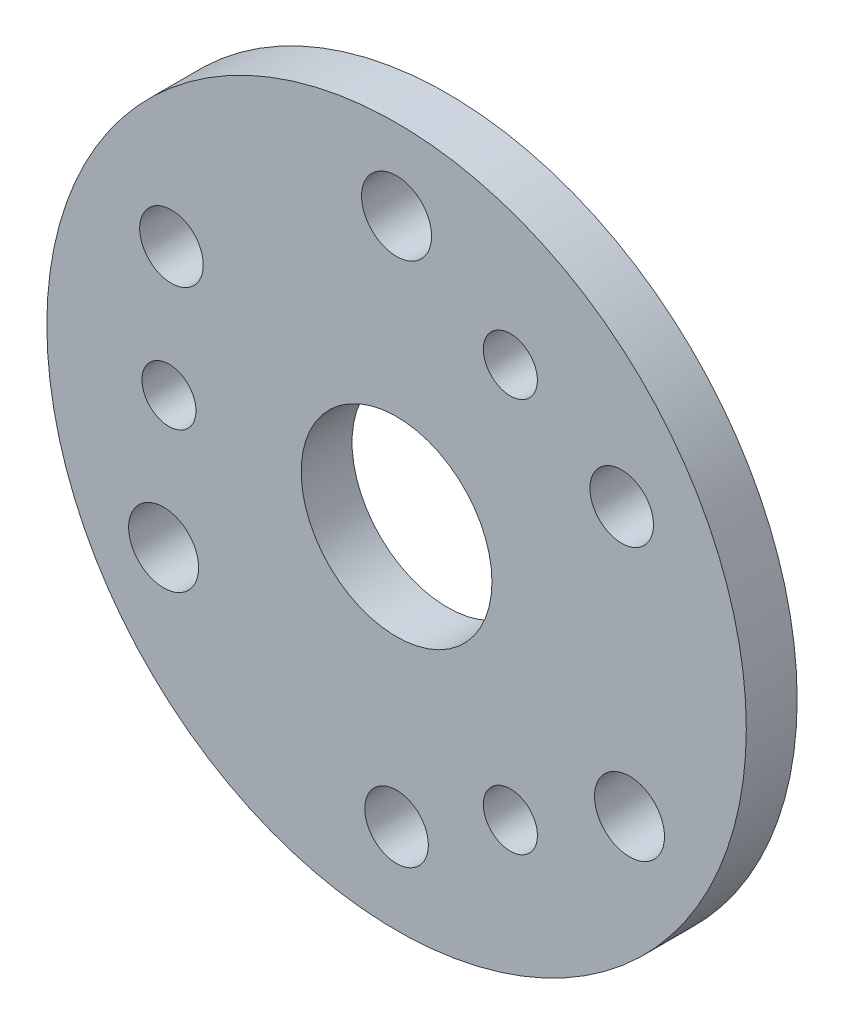
from build123d import *

# Parameters (mm, degrees)
ESQUISSE1_R        = 55
ESQUISSE1_R_2      = 15
ESQUISSE1_R_3      = 5.5
ESQUISSE1_R_4      = 4.25
ESQUISSE1_R_5      = 5
BOSS_EXTRU_1_DEPTH = 8


with BuildPart() as part:
    # Esquisse1 → Boss.-Extru.1 (new body)
    with BuildSketch(Plane.XY):
        Circle(ESQUISSE1_R)
        Circle(ESQUISSE1_R_2, mode=Mode.SUBTRACT)
        with Locations((0, 42.3)):
            Circle(ESQUISSE1_R_3, mode=Mode.SUBTRACT)
        with Locations((17.897858345, 31)):
            Circle(ESQUISSE1_R_4, mode=Mode.SUBTRACT)
        with Locations((35.4, 20.438199529)):
            Circle(ESQUISSE1_R_5, mode=Mode.SUBTRACT)
        with Locations((36.63287458, -21.15)):
            Circle(ESQUISSE1_R_3, mode=Mode.SUBTRACT)
        with Locations((17.897858345, -31)):
            Circle(ESQUISSE1_R_4, mode=Mode.SUBTRACT)
        with Locations((0, -40.876399059)):
            Circle(ESQUISSE1_R_5, mode=Mode.SUBTRACT)
        with Locations((-36.63287458, -21.15)):
            Circle(ESQUISSE1_R_3, mode=Mode.SUBTRACT)
        with Locations((-35.79571669, 0)):
            Circle(ESQUISSE1_R_4, mode=Mode.SUBTRACT)
        with Locations((-35.4, 20.438199529)):
            Circle(ESQUISSE1_R_5, mode=Mode.SUBTRACT)
    extrude(amount=BOSS_EXTRU_1_DEPTH)


solid = part.part
